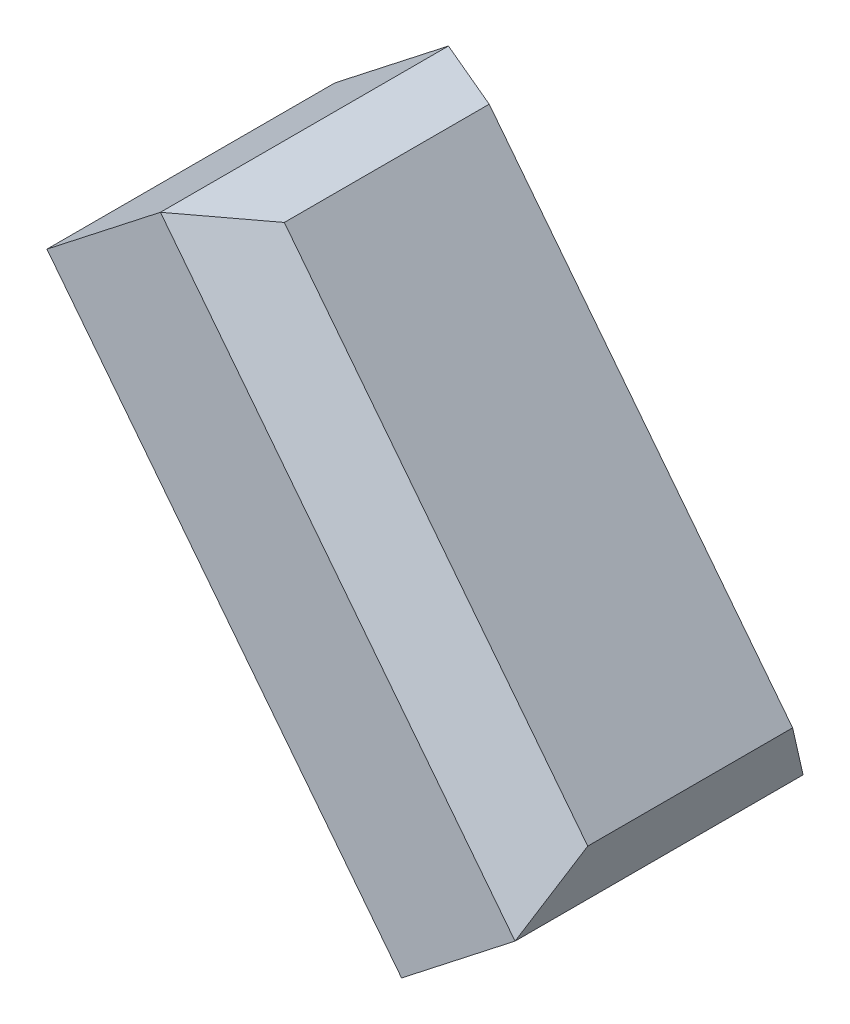
from build123d import *

# Parameters (mm, degrees)
SKETCH2_W             = 40
SKETCH2_H             = 80
BOSS_EXTRUDE1_DEPTH   = 30
CHAMFER1_SIZE         = 10
CHAMFER1_SIZE2        = 5.773502692
CHAMFER1_PART_2_SIZE  = 10
CHAMFER1_PART_2_SIZE2 = 5.773502692
CHAMFER1_PART_3_SIZE  = 10
CHAMFER1_PART_3_SIZE2 = 5.773502692
CHAMFER1_PART_4_SIZE  = 10
CHAMFER1_PART_4_SIZE2 = 5.773502692


with BuildPart() as part:
    # Sketch2 → Boss-Extrude1 (new body)
    with BuildSketch(Plane(origin=(0, 0, 0), x_dir=(0, 0, -1), z_dir=(0.788010754, 0.615661475, 0))):
        with Locations((20, 40)):
            Rectangle(SKETCH2_W, SKETCH2_H)
    extrude(amount=BOSS_EXTRUDE1_DEPTH)

    # Chamfer1
    chamfer1_edges = [part.edges().sort_by_distance(p)[0] for p in [
        (-0.986136405, 49.990274404, -40),
    ]]
    chamfer1_side = [part.faces().sort_by_distance(p)[0] for p in [
        (-12.806297709, 40.755352274, -40),
    ]]
    chamfer(chamfer1_edges, length=CHAMFER1_SIZE, length2=CHAMFER1_SIZE2, reference=chamfer1_side[0])

    # Chamfer1 part 2
    chamfer1_part_2_edges = [part.edges().sort_by_distance(p)[0] for p in [
        (-25.612595418, 81.510704548, -20),
    ]]
    chamfer1_part_2_side = [part.faces().sort_by_distance(p)[0] for p in [
        (-37.432756722, 72.275782418, -20),
    ]]
    chamfer(chamfer1_part_2_edges, length=CHAMFER1_PART_2_SIZE, length2=CHAMFER1_PART_2_SIZE2, reference=chamfer1_part_2_side[0])

    # Chamfer1 part 3
    chamfer1_part_3_edges = [part.edges().sort_by_distance(p)[0] for p in [
        (-0.986136405, 49.990274404, 0),
    ]]
    chamfer1_part_3_side = [part.faces().sort_by_distance(p)[0] for p in [
        (-12.806297709, 40.755352274, 0),
    ]]
    chamfer(chamfer1_part_3_edges, length=CHAMFER1_PART_3_SIZE, length2=CHAMFER1_PART_3_SIZE2, reference=chamfer1_part_3_side[0])

    # Chamfer1 part 4
    chamfer1_part_4_edges = [part.edges().sort_by_distance(p)[0] for p in [
        (23.640322608, 18.46984426, -20),
    ]]
    chamfer1_part_4_side = [part.faces().sort_by_distance(p)[0] for p in [
        (11.820161304, 9.23492213, -20),
    ]]
    chamfer(chamfer1_part_4_edges, length=CHAMFER1_PART_4_SIZE, length2=CHAMFER1_PART_4_SIZE2, reference=chamfer1_part_4_side[0])


solid = part.part
